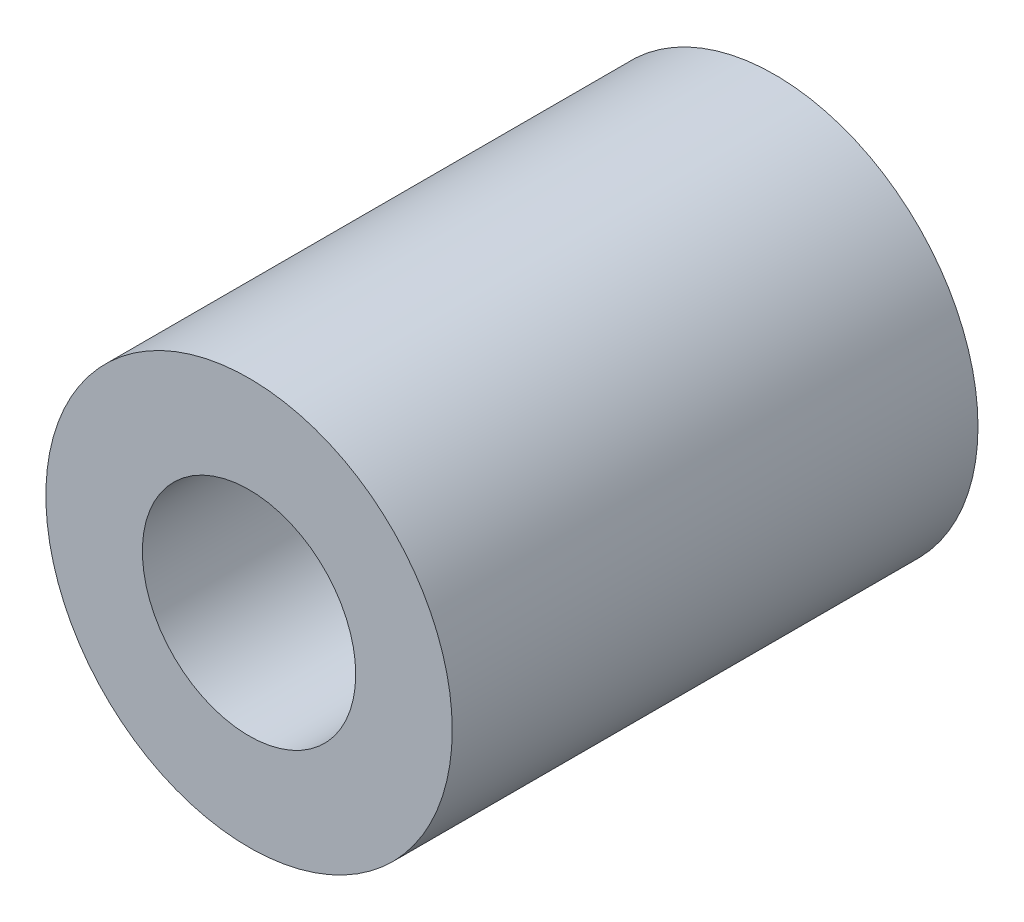
from build123d import *

# Parameters (mm, degrees)
SKETCH_1_R      = 4
SKETCH_1_R_2    = 2.1
EXTRUDE_1_DEPTH = 10.35


with BuildPart() as part:
    # ｽｹｯﾁ1 → ﾎﾞｽ - 押し出し1 (new body)
    with BuildSketch(Plane.XY):
        Circle(SKETCH_1_R)
        Circle(SKETCH_1_R_2, mode=Mode.SUBTRACT)
    extrude(amount=EXTRUDE_1_DEPTH)


solid = part.part
